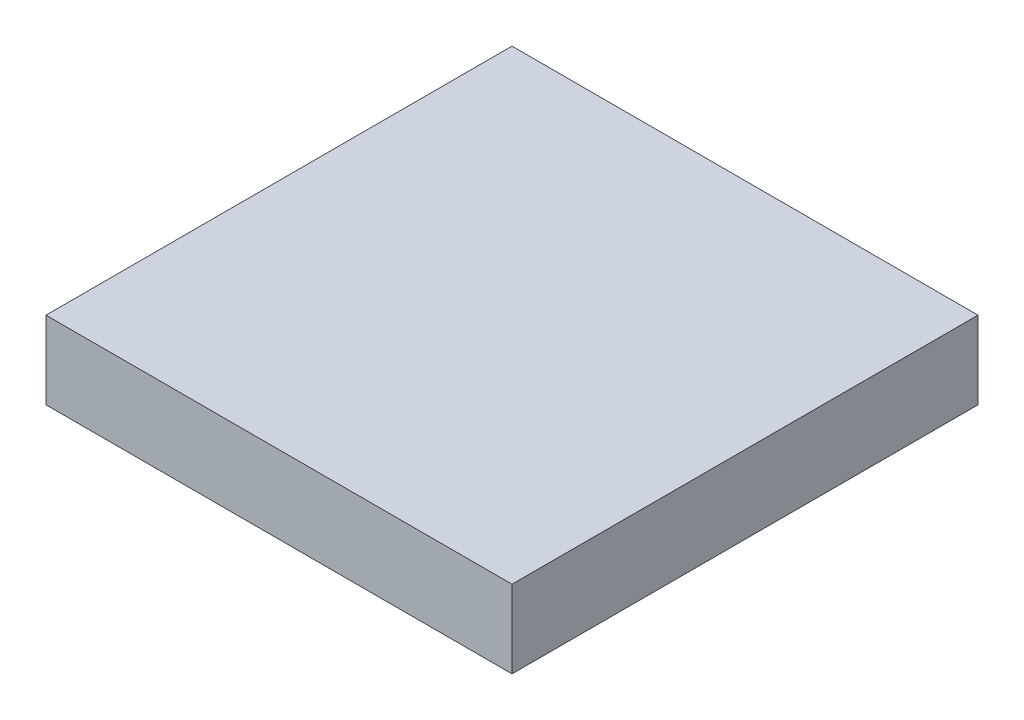
from build123d import *

# Parameters (mm, degrees)
SKETCH2_W           = 30
SKETCH2_H           = 30
BOSS_EXTRUDE1_DEPTH = 5


with BuildPart() as part:
    # Sketch2 → Boss-Extrude1 (new body)
    with BuildSketch(Plane(origin=(0, 0, 0), x_dir=(1, 0, 0), z_dir=(0, 1, 0))):
        Rectangle(SKETCH2_W, SKETCH2_H)
    extrude(amount=BOSS_EXTRUDE1_DEPTH)


solid = part.part
